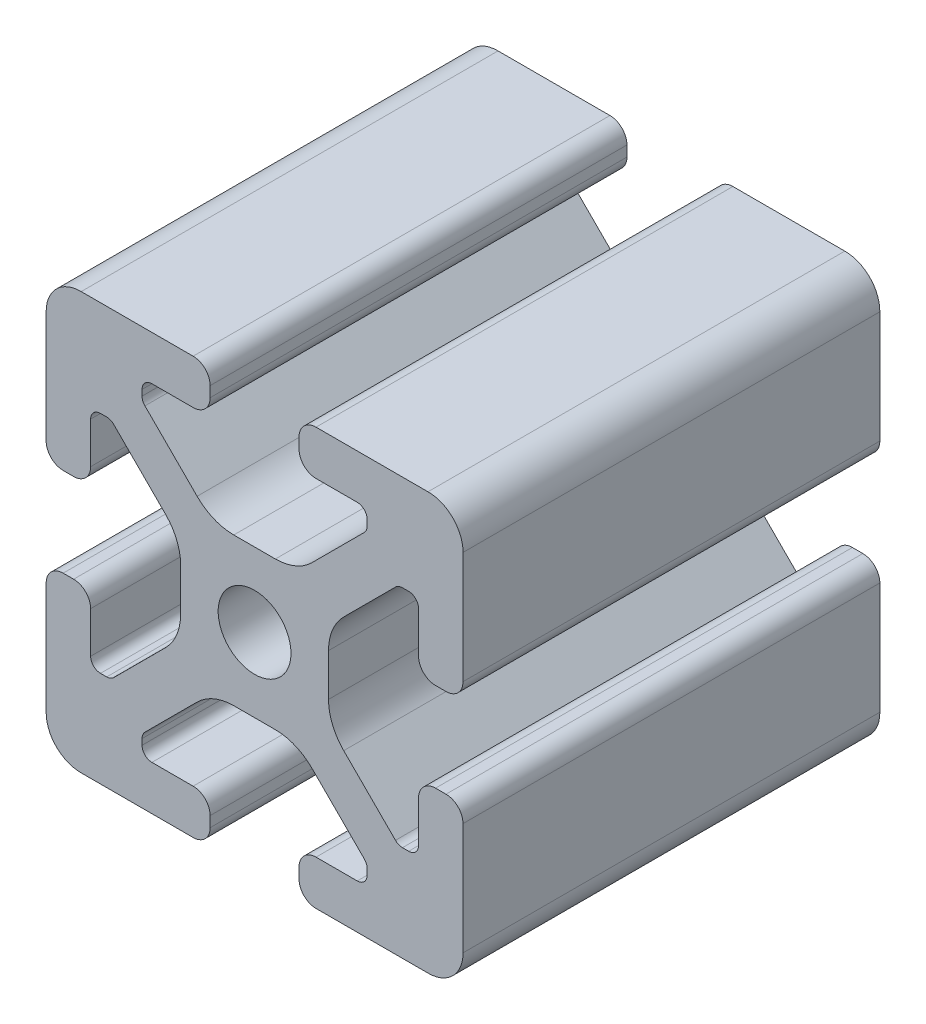
from build123d import *

# Parameters (mm, degrees)
SKETCH1_R           = 3.3274
BOSS_EXTRUDE1_DEPTH = 19.05


with BuildPart() as part:
    # Sketch1 → Boss-Extrude1 (new body, symmetric)
    with BuildSketch(Plane.XY):
        with BuildLine():
            Line((-4.064, 16.539617552), (-4.064, 17.496382454))
            ThreePointArc((-4.064, 17.496382454), (-4.519044044, 18.594955958), (-5.617617547, 19.050000004))
            Line((-5.617617547, 19.050000004), (-15.84748704, 19.050000004))
            ThreePointArc((-15.84748704, 19.050000004), (-18.12017629, 18.120192086), (-19.050000001, 15.847509297))
            Line((-19.050000001, 15.847509297), (-19.050000001, 5.617617549))
            ThreePointArc((-19.050000001, 5.617617549), (-18.594955957, 4.519044045), (-17.496382454, 4.064))
            Line((-17.496382454, 4.064), (-16.539617549, 4.064))
            ThreePointArc((-16.539617549, 4.064), (-15.441044044, 4.519044045), (-14.986, 5.617617549))
            Line((-14.986, 5.617617549), (-14.986, 9.385342517))
            ThreePointArc((-14.986, 9.385342517), (-14.721898184, 10.022940701), (-14.0843, 10.287042517))
            Line((-14.0843, 10.287042517), (-13.516042086, 10.287042517))
            ThreePointArc((-13.516042086, 10.287042517), (-13.170975923, 10.218404479), (-12.878443117, 10.022939917))
            Line((-12.878443117, 10.022939917), (-8.14758008, 5.292065242))
            ThreePointArc((-8.14758008, 5.292065242), (-7.117955877, 3.751120652), (-6.756399998, 1.933453582))
            Line((-6.756399998, 1.933453582), (-6.756399998, -1.933453584))
            ThreePointArc((-6.756399998, -1.933453584), (-7.117955877, -3.751120652), (-8.147580078, -5.292065242))
            Line((-8.147580078, -5.292065242), (-12.878443116, -10.022939917))
            ThreePointArc((-12.878443116, -10.022939917), (-13.170975922, -10.21840448), (-13.516042086, -10.287042518))
            Line((-13.516042086, -10.287042518), (-14.0843, -10.287042518))
            ThreePointArc((-14.0843, -10.287042518), (-14.721898185, -10.022940703), (-14.986, -9.385342518))
            Line((-14.986, -9.385342518), (-14.986, -5.617617549))
            ThreePointArc((-14.986, -5.617617549), (-15.441044044, -4.519044046), (-16.539617547, -4.064))
            Line((-16.539617547, -4.064), (-17.496382452, -4.064))
            ThreePointArc((-17.496382452, -4.064), (-18.594955956, -4.519044044), (-19.050000001, -5.617617547))
            Line((-19.050000001, -5.617617547), (-19.050000001, -15.84751072))
            ThreePointArc((-19.050000001, -15.84751072), (-18.120175718, -18.120192644), (-15.84748687, -19.050000001))
            Line((-15.84748687, -19.050000001), (-5.617617549, -19.050000001))
            ThreePointArc((-5.617617549, -19.050000001), (-4.519044046, -18.594955957), (-4.064, -17.496382454))
            Line((-4.064, -17.496382454), (-4.064, -16.539617549))
            ThreePointArc((-4.064, -16.539617549), (-4.519044045, -15.441044044), (-5.617617549, -14.985999999))
            Line((-5.617617549, -14.985999999), (-9.3853, -14.985999999))
            ThreePointArc((-9.3853, -14.985999999), (-10.022898185, -14.721898184), (-10.287, -14.084299999))
            Line((-10.287, -14.084299999), (-10.287, -13.552357131))
            ThreePointArc((-10.287, -13.552357131), (-10.218362387, -13.207291993), (-10.022898969, -12.914759731))
            Line((-10.022898969, -12.914759731), (-5.252158104, -8.14400713))
            ThreePointArc((-5.252158104, -8.14400713), (-3.715177371, -7.117027388), (-1.902183976, -6.7564))
            Line((-1.902183976, -6.7564), (1.902183976, -6.7564))
            ThreePointArc((1.902183976, -6.7564), (3.715177372, -7.117027388), (5.252158106, -8.144007132))
            Line((5.252158106, -8.144007132), (10.022898969, -12.91475973))
            ThreePointArc((10.022898969, -12.91475973), (10.218362387, -13.207291993), (10.287000001, -13.552357132))
            Line((10.287000001, -13.552357132), (10.287000001, -14.0843))
            ThreePointArc((10.287000001, -14.0843), (10.022898185, -14.721898184), (9.385300001, -14.986))
            Line((9.385300001, -14.986), (5.617617549, -14.986))
            ThreePointArc((5.617617549, -14.986), (4.519044045, -15.441044044), (4.064, -16.539617547))
            Line((4.064, -16.539617547), (4.064, -17.496382452))
            ThreePointArc((4.064, -17.496382452), (4.519044043, -18.594955955), (5.617617546, -19.050000001))
            Line((5.617617546, -19.050000001), (15.847486867, -19.050000001))
            ThreePointArc((15.847486867, -19.050000001), (18.120175716, -18.120192646), (19.05, -15.847510723))
            Line((19.05, -15.847510723), (19.05, -5.617617549))
            ThreePointArc((19.05, -5.617617549), (18.594955955, -4.519044045), (17.496382451, -4.064))
            Line((17.496382451, -4.064), (16.539617548, -4.064))
            ThreePointArc((16.539617548, -4.064), (15.441044044, -4.519044045), (14.985999999, -5.617617549))
            Line((14.985999999, -5.617617549), (14.985999999, -9.385342517))
            ThreePointArc((14.985999999, -9.385342517), (14.721898184, -10.022940701), (14.084299999, -10.287042517))
            Line((14.084299999, -10.287042517), (13.516042085, -10.287042517))
            ThreePointArc((13.516042085, -10.287042517), (13.170975922, -10.218404479), (12.878443117, -10.022939917))
            Line((12.878443117, -10.022939917), (8.147580079, -5.292065242))
            ThreePointArc((8.147580079, -5.292065242), (7.117955877, -3.751120652), (6.756399998, -1.933453583))
            Line((6.756399998, -1.933453583), (6.756399998, 1.933453583))
            ThreePointArc((6.756399998, 1.933453583), (7.117955877, 3.751120652), (8.147580078, 5.292065242))
            Line((8.147580078, 5.292065242), (12.878443116, 10.022939916))
            ThreePointArc((12.878443116, 10.022939916), (13.170975922, 10.218404477), (13.516042084, 10.287042515))
            Line((13.516042084, 10.287042515), (14.084299998, 10.287042515))
            ThreePointArc((14.084299998, 10.287042515), (14.721898183, 10.0229407), (14.985999998, 9.385342515))
            Line((14.985999998, 9.385342515), (14.985999998, 5.617617546))
            ThreePointArc((14.985999998, 5.617617546), (15.441044043, 4.519044042), (16.539617547, 4.063999997))
            Line((16.539617547, 4.063999997), (17.49638245, 4.063999997))
            ThreePointArc((17.49638245, 4.063999997), (18.594955956, 4.519044042), (19.05, 5.617617548))
            Line((19.05, 5.617617548), (19.05, 15.8475093))
            ThreePointArc((19.05, 15.8475093), (18.120176289, 18.120192086), (15.847487041, 19.050000004))
            Line((15.847487041, 19.050000004), (5.617617548, 19.050000004))
            ThreePointArc((5.617617548, 19.050000004), (4.519044044, 18.594955959), (4.063999999, 17.496382454))
            Line((4.063999999, 17.496382454), (4.063999999, 16.539617552))
            ThreePointArc((4.063999999, 16.539617552), (4.519044044, 15.441044047), (5.617617548, 14.986000002))
            Line((5.617617548, 14.986000002), (9.385299999, 14.986000002))
            ThreePointArc((9.385299999, 14.986000002), (10.022898183, 14.721898187), (10.286999999, 14.084300002))
            Line((10.286999999, 14.084300002), (10.286999999, 13.552357134))
            ThreePointArc((10.286999999, 13.552357134), (10.218362386, 13.207291996), (10.022898968, 12.914759734))
            Line((10.022898968, 12.914759734), (5.252158103, 8.144007133))
            ThreePointArc((5.252158103, 8.144007133), (3.71517737, 7.117027391), (1.902183975, 6.756400003))
            Line((1.902183975, 6.756400003), (-1.902183977, 6.756400003))
            ThreePointArc((-1.902183977, 6.756400003), (-3.715177373, 7.117027391), (-5.252158106, 8.144007134))
            Line((-5.252158106, 8.144007134), (-10.022898969, 12.914759733))
            ThreePointArc((-10.022898969, 12.914759733), (-10.218362387, 13.207291995), (-10.287000001, 13.552357134))
            Line((-10.287000001, 13.552357134), (-10.287000001, 14.084300002))
            ThreePointArc((-10.287000001, 14.084300002), (-10.022898186, 14.721898187), (-9.385300001, 14.986000002))
            Line((-9.385300001, 14.986000002), (-5.617617549, 14.986000002))
            ThreePointArc((-5.617617549, 14.986000002), (-4.519044044, 15.441044047), (-4.064, 16.539617552))
        make_face()
        Circle(SKETCH1_R, mode=Mode.SUBTRACT)
    extrude(amount=BOSS_EXTRUDE1_DEPTH, both=True)


solid = part.part
